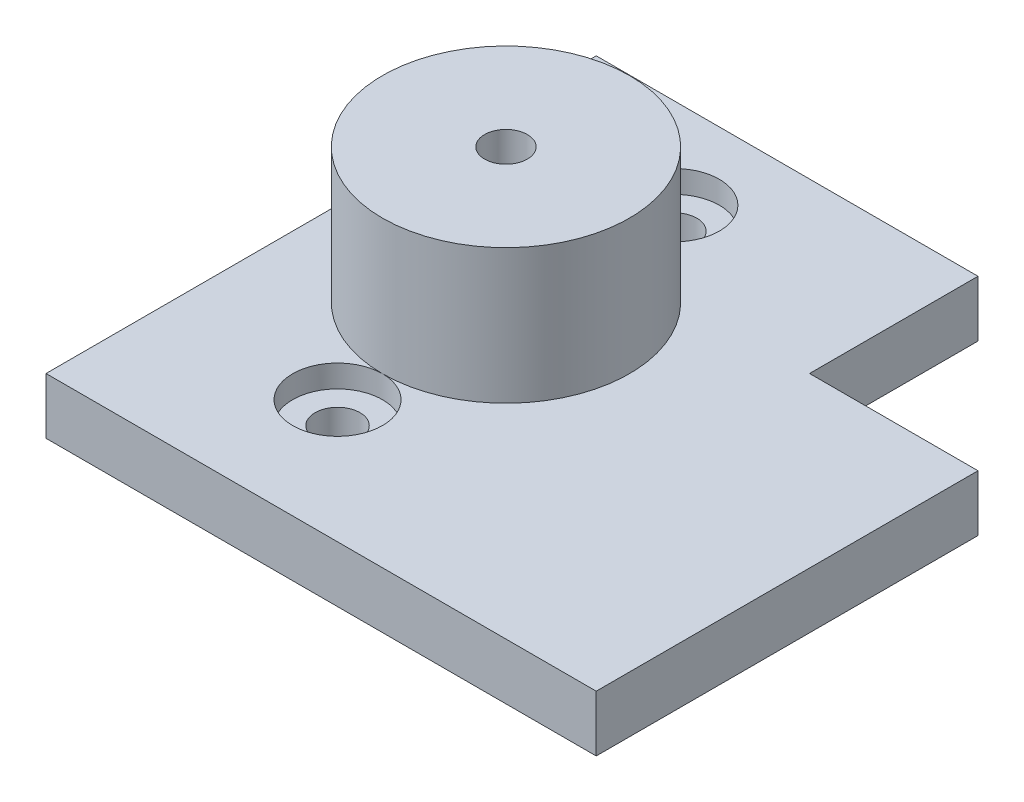
from build123d import *

# Parameters (mm, degrees)
SKETCH1_R           = 2
BOSS_EXTRUDE1_DEPTH = 5
SKETCH2_R           = 4
CUT_EXTRUDE1_DEPTH  = 2
SKETCH3_R           = 11
SKETCH3_R_2         = 1.901621635
BOSS_EXTRUDE2_DEPTH = 12


with BuildPart() as part:
    # Sketch1 → Boss-Extrude1 (new body)
    with BuildSketch(Plane(origin=(0, 0, 0), x_dir=(1, 0, 0), z_dir=(0, 1, 0))):
        Polygon((0, 49), (0, 0), (49, 0), (49, 34), (34, 34), (34, 49), align=None)
        with Locations((15, 10.96347032)):
            Circle(SKETCH1_R, mode=Mode.SUBTRACT)
        with Locations((15, 25.96347032)):
            Circle(SKETCH1_R, mode=Mode.SUBTRACT)
        with Locations((15, 40.96347032)):
            Circle(SKETCH1_R, mode=Mode.SUBTRACT)
    extrude(amount=BOSS_EXTRUDE1_DEPTH)

    # Sketch2 → Cut-Extrude1 (cut)
    with BuildSketch(Plane(origin=(0, 5, 0), x_dir=(1, 0, 0), z_dir=(0, 1, 0))):
        with Locations((15, 40.96347032)):
            Circle(SKETCH2_R)
        with Locations((15, 10.96347032)):
            Circle(SKETCH2_R)
    extrude(amount=-CUT_EXTRUDE1_DEPTH, mode=Mode.SUBTRACT)

    # Sketch3 → Boss-Extrude2 (add)
    with BuildSketch(Plane(origin=(0, 5, 0), x_dir=(1, 0, 0), z_dir=(0, 1, 0))):
        with Locations((15, 25.96347032)):
            Circle(SKETCH3_R)
        with Locations((15, 25.96347032)):
            Circle(SKETCH3_R_2, mode=Mode.SUBTRACT)
    extrude(amount=BOSS_EXTRUDE2_DEPTH)


solid = part.part
